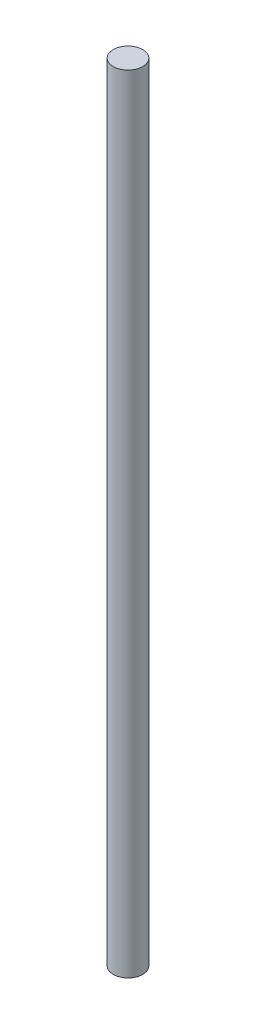
from build123d import *

# Parameters (mm, degrees)
SKETCH1_R           = 1.5
BOSS_EXTRUDE1_DEPTH = 40


with BuildPart() as part:
    # Sketch1 → Boss-Extrude1 (new body, symmetric)
    with BuildSketch(Plane(origin=(0, 0, 0), x_dir=(1, 0, 0), z_dir=(0, 1, 0))):
        Circle(SKETCH1_R)
    extrude(amount=BOSS_EXTRUDE1_DEPTH, both=True)


solid = part.part
